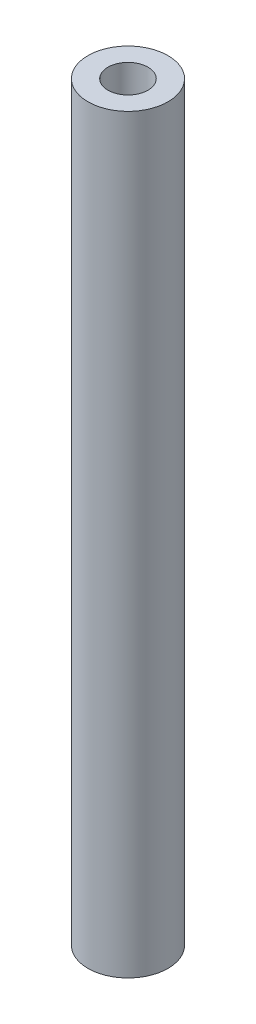
from build123d import *

# Parameters (mm, degrees)
SKETCH_1_R          = 4
EXTRUDE_1_DEPTH     = 75
SKETCH_2_R          = 2
CUT_EXTRUDE_1_DEPTH = 4
SKETCH_3_R          = 2
CUT_EXTRUDE_2_DEPTH = 4


with BuildPart() as part:
    # 草圖1 → 填料-伸長1 (new body)
    with BuildSketch(Plane(origin=(0, 0, 0), x_dir=(1, 0, 0), z_dir=(0, 1, 0))):
        Circle(SKETCH_1_R)
    extrude(amount=EXTRUDE_1_DEPTH)

    # 草圖2 → 除料-伸長1 (cut)
    with BuildSketch(Plane(origin=(0, 75, 0), x_dir=(1, 0, 0), z_dir=(0, 1, 0))):
        Circle(SKETCH_2_R)
    extrude(amount=-CUT_EXTRUDE_1_DEPTH, mode=Mode.SUBTRACT)

    # 草圖3 → 除料-伸長2 (cut)
    with BuildSketch(Plane.XZ):
        Circle(SKETCH_3_R)
    extrude(amount=-CUT_EXTRUDE_2_DEPTH, mode=Mode.SUBTRACT)


solid = part.part
